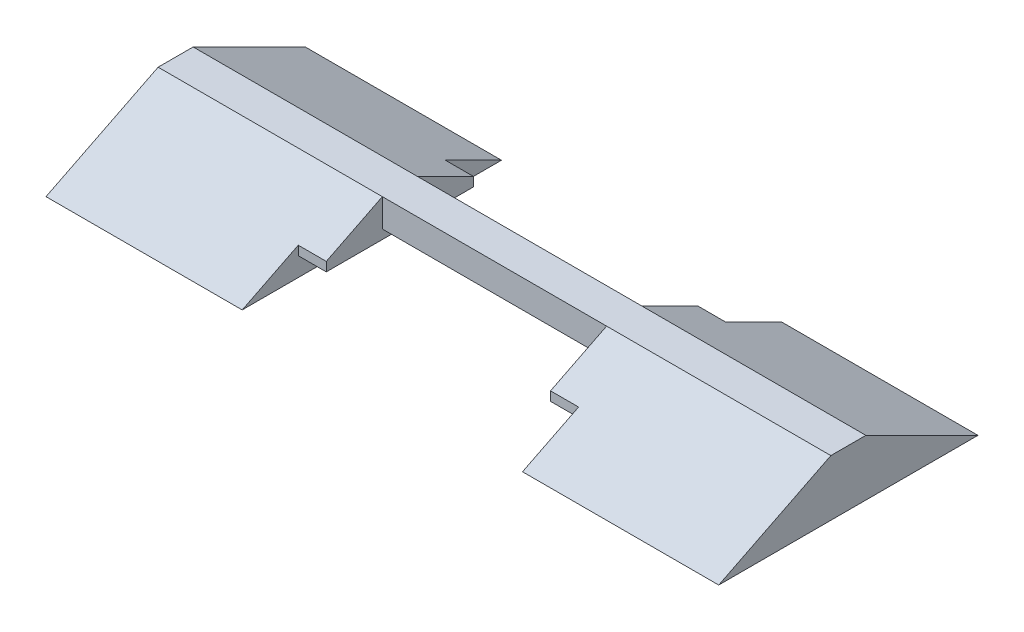
from build123d import *

# Parameters (mm, degrees)
BOSS_EXTRUDE1_DEPTH  = 1.25
SKETCH2_W            = 1
SKETCH2_H            = 0.325
BOSS_EXTRUDE2_DEPTH  = 2
SKETCH3_W            = 1
SKETCH3_H            = 0.325
BOSS_EXTRUDE3_DEPTH  = 2
BOSS_EXTRUDE7_DEPTH  = 1
BOSS_EXTRUDE8_DEPTH  = 1
BOSS_EXTRUDE9_DEPTH  = 7
BOSS_EXTRUDE10_DEPTH = 7


with BuildPart() as part:
    # Sketch1 → Boss-Extrude1 (new body)
    with BuildSketch(Plane.XY):
        Polygon((1, 0), (9, 0), (9, -0.325), (10, -0.325), (10, -1), (17, -1), (17, 1), (10, 1), (0, 1), (-7, 1), (-7, -1), (0, -1), (0, -0.325), (1, -0.325), align=None)
    extrude(amount=BOSS_EXTRUDE1_DEPTH)

    # Sketch2 → Boss-Extrude2 (add)
    with BuildSketch(Plane.XY.offset(1.25)):
        with Locations((0.5, -0.1625)):
            Rectangle(SKETCH2_W, SKETCH2_H)
        with Locations((9.5, -0.1625)):
            Rectangle(SKETCH2_W, SKETCH2_H)
    extrude(amount=BOSS_EXTRUDE2_DEPTH)

    # Sketch3 → Boss-Extrude3 (add)
    with BuildSketch(Plane(origin=(0, 0, 0), x_dir=(-1, 0, 0), z_dir=(0, 0, -1))):
        with Locations((-9.5, -0.1625)):
            Rectangle(SKETCH3_W, SKETCH3_H)
        with Locations((-0.5, -0.1625)):
            Rectangle(SKETCH3_W, SKETCH3_H)
    extrude(amount=BOSS_EXTRUDE3_DEPTH)

    # Sketch7 → Boss-Extrude7 (add)
    with BuildSketch(Plane(origin=(10, 0, 0), x_dir=(0, 0, -1), z_dir=(1, 0, 0))):
        Polygon((-3.25, 0), (-1.25, 1), (-1.25, 0), (-1.25, -0.325), (-3.25, -0.325), align=None)
        Polygon((2, 0), (0, 1), (0, 0), align=None)
    extrude(amount=-BOSS_EXTRUDE7_DEPTH)

    # Sketch8 → Boss-Extrude8 (add)
    with BuildSketch(Plane.ZY):
        Polygon((-2, 0), (0, 1), (0, 0), align=None)
        Polygon((1.25, 1), (1.25, 0), (3.25, 0), align=None)
    extrude(amount=-BOSS_EXTRUDE8_DEPTH)

    # Sketch10 → Boss-Extrude9 (add)
    with BuildSketch(Plane.ZY):
        Polygon((1.25, 1), (3.25, 0), (5.25, -1), (1.25, -1), align=None)
        Polygon((0, 1), (-2, 0), (-4, -1), (0, -1), align=None)
    extrude(amount=BOSS_EXTRUDE9_DEPTH)

    # Sketch11 → Boss-Extrude10 (add)
    with BuildSketch(Plane(origin=(10, 0, 0), x_dir=(0, 0, -1), z_dir=(1, 0, 0))):
        Polygon((-1.25, 1), (-5.25, -1), (-1.25, -1), align=None)
        Polygon((0, 1), (4, -1), (0, -1), align=None)
    extrude(amount=BOSS_EXTRUDE10_DEPTH)


solid = part.part
